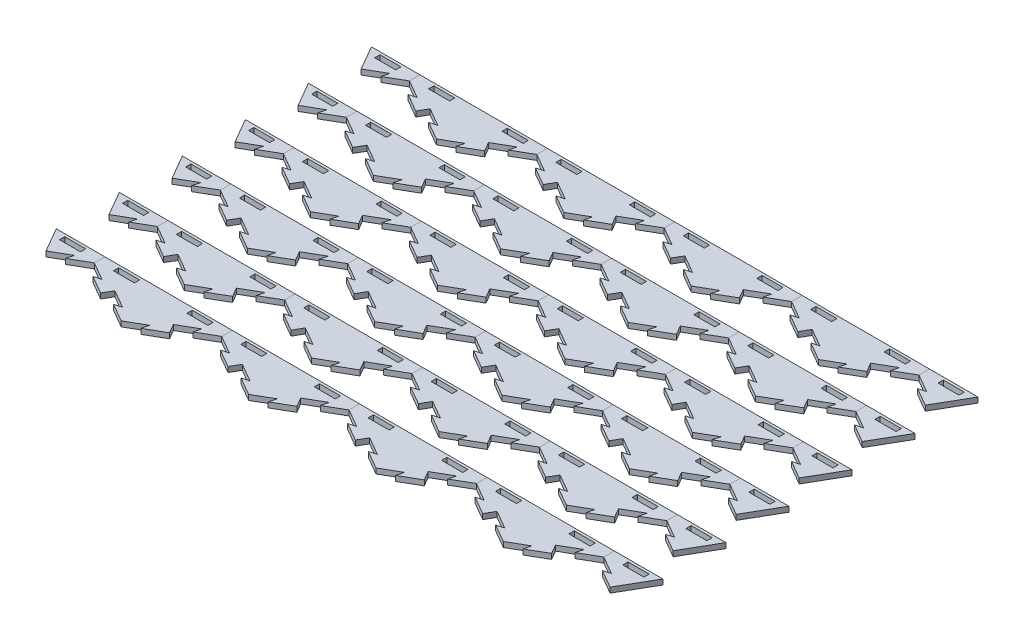
from build123d import *

# Parameters (mm, degrees)
BOSS_EXTRUDE1_DEPTH = 6.35
CUT_EXTRUDE4_DEPTH  = 155.110195964
BOSS_EXTRUDE4_DEPTH = 6.35
CIRPATTERN1_COUNT   = 2
CIRPATTERN1_ANGLE   = 60
SKETCH12_W          = 153.979316792
SKETCH12_H          = 120.65
CUT_EXTRUDE5_DEPTH  = 155.110195964
SKETCH13_W          = 25.4
SKETCH13_H          = 6.35
CUT_EXTRUDE6_DEPTH  = 90.126497182
LPATTERN1_COUNT     = 5
LPATTERN1_PITCH     = 153.979316882
LPATTERN1_2_COUNT   = 2
LPATTERN1_2_PITCH   = 153.979316882
SKETCH14_W          = 25.4
SKETCH14_H          = 6.35
SKETCH14_W_2        = 76.989658396
SKETCH14_H_2        = 57.15
CUT_EXTRUDE7_DEPTH  = 695.360232872
LPATTERN2_COUNT     = 6
LPATTERN2_PITCH     = 76.2


with BuildPart() as part:
    # Sketch1 → Boss-Extrude1 (new body)
    with BuildSketch(Plane(origin=(0, 0, 0), x_dir=(1, 0, 0), z_dir=(0, 1, 0))):
        Polygon((-76.989658396, 0), (0, -44.45), (76.989658396, 0), (76.989658396, 88.9), (0, 133.35), (-76.989658396, 88.9), align=None)
    extrude(amount=-BOSS_EXTRUDE1_DEPTH)

    # Sketch10 → Cut-Extrude4 (cut, through all)
    with BuildSketch(Plane(origin=(0, 0, 0), x_dir=(1, 0, 0), z_dir=(0, 1, 0))):
        Polygon((-21.997045256, -31.75), (-13.322783942, -29.425738686), (-35.319829198, -16.725738686), (-38.494829198, -22.225), align=None)
    cut_extrude4 = extrude(amount=-CUT_EXTRUDE4_DEPTH, mode=Mode.SUBTRACT)

    # Sketch11 → Boss-Extrude4 (add)
    with BuildSketch(Plane(origin=(0, 0, 0), x_dir=(1, 0, 0), z_dir=(0, 1, 0))):
        Polygon((-38.494829198, -22.225), (-41.669829198, -27.724261314), (-63.666874454, -15.024261314), (-54.99261314, -12.7), align=None)
    boss_extrude4 = extrude(amount=-BOSS_EXTRUDE4_DEPTH)

    # CirPattern1: Cut-Extrude4, Boss-Extrude4 ×2 about axis
    cirpattern1_axis = Axis((0, 0, -44.45), (0, 1, 0))
    add([cut_extrude4.rotate(cirpattern1_axis, i * CIRPATTERN1_ANGLE / (CIRPATTERN1_COUNT - 1)) for i in range(1, CIRPATTERN1_COUNT)], mode=Mode.SUBTRACT)
    add([boss_extrude4.rotate(cirpattern1_axis, i * CIRPATTERN1_ANGLE / (CIRPATTERN1_COUNT - 1)) for i in range(1, CIRPATTERN1_COUNT)])

    # Sketch12 → Cut-Extrude5 (cut, through all)
    with BuildSketch(Plane(origin=(0, 0, 0), x_dir=(1, 0, 0), z_dir=(0, 1, 0))):
        with Locations((0, 73.025)):
            Rectangle(SKETCH12_W, SKETCH12_H)
    extrude(amount=-CUT_EXTRUDE5_DEPTH, mode=Mode.SUBTRACT)

    # Sketch13 → Cut-Extrude6 (cut, through all)
    with BuildSketch(Plane(origin=(0, 0, 0), x_dir=(1, 0, 0), z_dir=(0, 1, 0))):
        with Locations((-44.45, 6.35)):
            Rectangle(SKETCH13_W, SKETCH13_H)
        with Locations((44.45, 6.35)):
            Rectangle(SKETCH13_W, SKETCH13_H)
    extrude(amount=-CUT_EXTRUDE6_DEPTH, mode=Mode.SUBTRACT)


with BuildPart() as lpattern1_1:
    # LPattern1: pattern copy
    add(part.part.moved(Location(Vector(1, 0, 0) * (1 * LPATTERN1_PITCH))))


with BuildPart() as lpattern1_2:
    # LPattern1: pattern copy
    add(part.part.moved(Location(Vector(1, 0, 0) * (2 * LPATTERN1_PITCH))))


with BuildPart() as lpattern1_3:
    # LPattern1: pattern copy
    add(part.part.moved(Location(Vector(1, 0, 0) * (3 * LPATTERN1_PITCH))))


with BuildPart() as lpattern1_4:
    # LPattern1: pattern copy
    add(part.part.moved(Location(Vector(1, 0, 0) * (4 * LPATTERN1_PITCH))))


with BuildPart() as lpattern1_2_1:
    # LPattern1 2: pattern copy
    add(part.part.moved(Location(Vector(-1, 0, 0) * (1 * LPATTERN1_2_PITCH))))


with BuildPart() as cut_extrude7_tool:
    # Sketch14 → Cut-Extrude7 (new, through all)
    # profile 1 of 4: a face of its own
    with BuildSketch(Plane(origin=(0, 0, 0), x_dir=(1, 0, 0), z_dir=(0, 1, 0))):
        Polygon((-134.30653294, -40.424261314), (-153.979316882, -44.45), (-153.979316882, 12.7), (-135.648445835, 12.7), (-112.309487684, -27.724261314), align=None)
    # profile 2 of 4: a face of its own
    with BuildSketch(Plane(origin=(0, 0, 0), x_dir=(1, 0, 0), z_dir=(0, 1, 0))):
        Polygon((593.920222272, -31.75), (615.917267528, -44.45), (615.917267528, 12.7), (597.586396481, 12.7), (580.59743833, -16.725738686), (602.594483586, -29.425738686), align=None)
    # profile 3 of 4: a face of its own
    with BuildSketch(Plane(origin=(0, 0, 0), x_dir=(1, 0, 0), z_dir=(0, 1, 0))):
        Polygon((615.917267528, 12.7), (615.917267528, -44.45), (637.914312784, -31.75), (635.59005147, -40.424261314), (657.587096726, -27.724261314), (651.237096726, -16.725738686), (673.234141982, -4.025738686), (670.909880668, -12.7), (692.906925924, 0), (692.906925924, 12.7), align=None)
        with Locations((660.367267528, 6.35)):
            Rectangle(SKETCH14_W, SKETCH14_H, mode=Mode.SUBTRACT)
    # profile 4 of 4: a face of its own
    with BuildSketch(Plane(origin=(0, 0, 0), x_dir=(1, 0, 0), z_dir=(0, 1, 0))):
        with Locations((-192.47414608, -15.875)):
            Rectangle(SKETCH14_W_2, SKETCH14_H_2)
    extrude(amount=-CUT_EXTRUDE7_DEPTH)


with BuildPart() as lpattern1_4_1:
    add(lpattern1_4.part)

    # Cut-Extrude7: cut by cut_extrude7_tool
    add(cut_extrude7_tool.part, mode=Mode.SUBTRACT)


with BuildPart() as lpattern1_2_1_1:
    add(lpattern1_2_1.part)

    # Cut-Extrude7: cut by cut_extrude7_tool
    add(cut_extrude7_tool.part, mode=Mode.SUBTRACT)


with BuildPart() as lpattern2_1:
    # LPattern2: pattern copy
    add(lpattern1_4_1.part.moved(Location(Vector(0, 0, 1) * (1 * LPATTERN2_PITCH))))


with BuildPart() as lpattern2_2:
    # LPattern2: pattern copy
    add(lpattern1_4_1.part.moved(Location(Vector(0, 0, 1) * (2 * LPATTERN2_PITCH))))


with BuildPart() as lpattern2_3:
    # LPattern2: pattern copy
    add(lpattern1_4_1.part.moved(Location(Vector(0, 0, 1) * (3 * LPATTERN2_PITCH))))


with BuildPart() as lpattern2_4:
    # LPattern2: pattern copy
    add(lpattern1_4_1.part.moved(Location(Vector(0, 0, 1) * (4 * LPATTERN2_PITCH))))


with BuildPart() as lpattern2_5:
    # LPattern2: pattern copy
    add(lpattern1_4_1.part.moved(Location(Vector(0, 0, 1) * (5 * LPATTERN2_PITCH))))


with BuildPart() as lpattern2_6:
    # LPattern2: pattern copy
    add(lpattern1_3.part.moved(Location(Vector(0, 0, 1) * (1 * LPATTERN2_PITCH))))


with BuildPart() as lpattern2_7:
    # LPattern2: pattern copy
    add(lpattern1_3.part.moved(Location(Vector(0, 0, 1) * (2 * LPATTERN2_PITCH))))


with BuildPart() as lpattern2_8:
    # LPattern2: pattern copy
    add(lpattern1_3.part.moved(Location(Vector(0, 0, 1) * (3 * LPATTERN2_PITCH))))


with BuildPart() as lpattern2_9:
    # LPattern2: pattern copy
    add(lpattern1_3.part.moved(Location(Vector(0, 0, 1) * (4 * LPATTERN2_PITCH))))


with BuildPart() as lpattern2_10:
    # LPattern2: pattern copy
    add(lpattern1_3.part.moved(Location(Vector(0, 0, 1) * (5 * LPATTERN2_PITCH))))


with BuildPart() as lpattern2_11:
    # LPattern2: pattern copy
    add(lpattern1_2.part.moved(Location(Vector(0, 0, 1) * (1 * LPATTERN2_PITCH))))


with BuildPart() as lpattern2_12:
    # LPattern2: pattern copy
    add(lpattern1_2.part.moved(Location(Vector(0, 0, 1) * (2 * LPATTERN2_PITCH))))


with BuildPart() as lpattern2_13:
    # LPattern2: pattern copy
    add(lpattern1_2.part.moved(Location(Vector(0, 0, 1) * (3 * LPATTERN2_PITCH))))


with BuildPart() as lpattern2_14:
    # LPattern2: pattern copy
    add(lpattern1_2.part.moved(Location(Vector(0, 0, 1) * (4 * LPATTERN2_PITCH))))


with BuildPart() as lpattern2_15:
    # LPattern2: pattern copy
    add(lpattern1_2.part.moved(Location(Vector(0, 0, 1) * (5 * LPATTERN2_PITCH))))


with BuildPart() as lpattern2_16:
    # LPattern2: pattern copy
    add(lpattern1_1.part.moved(Location(Vector(0, 0, 1) * (1 * LPATTERN2_PITCH))))


with BuildPart() as lpattern2_17:
    # LPattern2: pattern copy
    add(lpattern1_1.part.moved(Location(Vector(0, 0, 1) * (2 * LPATTERN2_PITCH))))


with BuildPart() as lpattern2_18:
    # LPattern2: pattern copy
    add(lpattern1_1.part.moved(Location(Vector(0, 0, 1) * (3 * LPATTERN2_PITCH))))


with BuildPart() as lpattern2_19:
    # LPattern2: pattern copy
    add(lpattern1_1.part.moved(Location(Vector(0, 0, 1) * (4 * LPATTERN2_PITCH))))


with BuildPart() as lpattern2_20:
    # LPattern2: pattern copy
    add(lpattern1_1.part.moved(Location(Vector(0, 0, 1) * (5 * LPATTERN2_PITCH))))


with BuildPart() as lpattern2_21:
    # LPattern2: pattern copy
    add(part.part.moved(Location(Vector(0, 0, 1) * (1 * LPATTERN2_PITCH))))


with BuildPart() as lpattern2_22:
    # LPattern2: pattern copy
    add(part.part.moved(Location(Vector(0, 0, 1) * (2 * LPATTERN2_PITCH))))


with BuildPart() as lpattern2_23:
    # LPattern2: pattern copy
    add(part.part.moved(Location(Vector(0, 0, 1) * (3 * LPATTERN2_PITCH))))


with BuildPart() as lpattern2_24:
    # LPattern2: pattern copy
    add(part.part.moved(Location(Vector(0, 0, 1) * (4 * LPATTERN2_PITCH))))


with BuildPart() as lpattern2_25:
    # LPattern2: pattern copy
    add(part.part.moved(Location(Vector(0, 0, 1) * (5 * LPATTERN2_PITCH))))


with BuildPart() as lpattern2_26:
    # LPattern2: pattern copy
    add(lpattern1_2_1_1.part.moved(Location(Vector(0, 0, 1) * (1 * LPATTERN2_PITCH))))


with BuildPart() as lpattern2_27:
    # LPattern2: pattern copy
    add(lpattern1_2_1_1.part.moved(Location(Vector(0, 0, 1) * (2 * LPATTERN2_PITCH))))


with BuildPart() as lpattern2_28:
    # LPattern2: pattern copy
    add(lpattern1_2_1_1.part.moved(Location(Vector(0, 0, 1) * (3 * LPATTERN2_PITCH))))


with BuildPart() as lpattern2_29:
    # LPattern2: pattern copy
    add(lpattern1_2_1_1.part.moved(Location(Vector(0, 0, 1) * (4 * LPATTERN2_PITCH))))


with BuildPart() as lpattern2_30:
    # LPattern2: pattern copy
    add(lpattern1_2_1_1.part.moved(Location(Vector(0, 0, 1) * (5 * LPATTERN2_PITCH))))


solid = Compound([part.part, lpattern1_1.part, lpattern1_2.part, lpattern1_3.part, lpattern1_4_1.part, lpattern1_2_1_1.part, lpattern2_1.part, lpattern2_2.part, lpattern2_3.part, lpattern2_4.part, lpattern2_5.part, lpattern2_6.part, lpattern2_7.part, lpattern2_8.part, lpattern2_9.part, lpattern2_10.part, lpattern2_11.part, lpattern2_12.part, lpattern2_13.part, lpattern2_14.part, lpattern2_15.part, lpattern2_16.part, lpattern2_17.part, lpattern2_18.part, lpattern2_19.part, lpattern2_20.part, lpattern2_21.part, lpattern2_22.part, lpattern2_23.part, lpattern2_24.part, lpattern2_25.part, lpattern2_26.part, lpattern2_27.part, lpattern2_28.part, lpattern2_29.part, lpattern2_30.part])
